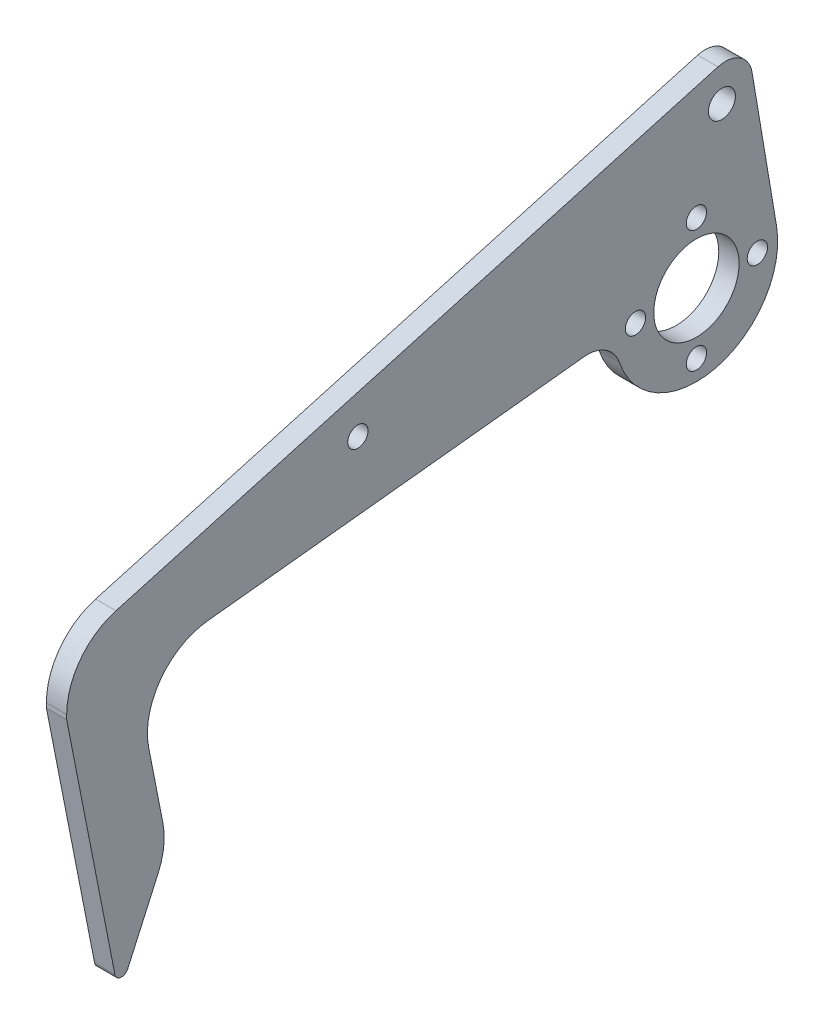
from build123d import *

# Parameters (mm, degrees)
SKETCH_1_R          = 12
SKETCH_1_R_2        = 1.5
SKETCH_1_R_3        = 6.3
EXTRUDE_1_DEPTH     = 3
EXTRUDE_2_DEPTH     = 3
FILLET_2_R          = 30
FILLET_4_R          = 1
SKETCH_3_R          = 1.5
CUT_EXTRUDE_1_DEPTH = 3
FILLET_6_R          = 3
SKETCH_5_R          = 2
EXTRUDE_3_DEPTH     = 3
FILLET_8_R          = 3
CUT_EXTRUDE_2_DEPTH = 10
EXTRUDE_4_DEPTH     = 3
CUT_EXTRUDE_4_DEPTH = 88.351282371
EXTRUDE_5_DEPTH     = 3
EXTRUDE_6_DEPTH     = 3
FILLET_9_R          = 10
FILLET_10_R         = 1
EXTRUDE_8_DEPTH     = 3
FILLET_11_R         = 5


with BuildPart() as part:
    # 草图1 → 凸台-拉伸1 (new body)
    with BuildSketch(Plane(origin=(0, 0, 0), x_dir=(0, 0, -1), z_dir=(1, 0, 0))):
        Circle(SKETCH_1_R)
        with Locations((0, 9)):
            Circle(SKETCH_1_R_2, mode=Mode.SUBTRACT)
        Circle(SKETCH_1_R_3, mode=Mode.SUBTRACT)
        with Locations((9, 0)):
            Circle(SKETCH_1_R_2, mode=Mode.SUBTRACT)
        with Locations((0, -9)):
            Circle(SKETCH_1_R_2, mode=Mode.SUBTRACT)
        with Locations((-9, 0)):
            Circle(SKETCH_1_R_2, mode=Mode.SUBTRACT)
    extrude(amount=EXTRUDE_1_DEPTH)

    # 草图4 → 凸台-拉伸2 (add)
    with BuildSketch(Plane.ZY):
        with BuildLine():
            Line((68.504845759, -22.032619578), (78, -30))
            Line((78, -30), (78, 3))
            Line((78, 3), (18.911534819, 13.41889066))
            Line((18.911534819, 13.41889066), (-0.877535827, 11.967870774))
            ThreePointArc((-0.877535827, 11.967870774), (8.169136125, 8.790063422), (12, 0))
            ThreePointArc((12, 0), (11.827182716, -2.029223745), (11.313708499, -4))
            Line((11.313708499, -4), (32.009040998, -6.929191455))
            Line((32.009040998, -6.929191455), (67.339599923, -4.571456898))
            Line((67.339599923, -4.571456898), (67.835333173, -12))
            Line((67.835333173, -12), (68.504845759, -22.032619578))
        make_face()
        Polygon((32.009040998, -6.929191455), (67.835333173, -12), (67.339599923, -4.571456898), align=None)
    extrude(amount=-EXTRUDE_2_DEPTH)

    # 圆角2
    fillet_2_edges = [part.edges().sort_by_distance(p)[0] for p in [
        (1.5, 13.41889066, 18.911534819),
    ]]
    fillet(fillet_2_edges, radius=FILLET_2_R)

    # 圆角4
    fillet_4_edges = [part.edges().sort_by_distance(p)[0] for p in [
        (1.5, -30, 78),
    ]]
    fillet(fillet_4_edges, radius=FILLET_4_R)

    # 草图3 → 切除-拉伸1 (cut)
    with BuildSketch(Plane.ZY):
        with Locations((50, 6)):
            Circle(SKETCH_3_R)
    extrude(amount=-CUT_EXTRUDE_1_DEPTH, mode=Mode.SUBTRACT)

    # 圆角6
    fillet_6_edges = [part.edges().sort_by_distance(p)[0] for p in [
        (1.5, -22.032619578, 68.504845759),
    ]]
    fillet(fillet_6_edges, radius=FILLET_6_R)

    # 草图5 → 凸台-拉伸3 (add)
    with BuildSketch(Plane(origin=(3, 0, 0), x_dir=(0, 0, -1), z_dir=(1, 0, 0))):
        with BuildLine():
            Line((11.833611983, 1.991388321), (8.212146403, 23.511559971))
            ThreePointArc((8.212146403, 23.511559971), (6.010394905, 26.448138505), (2.341304536, 26.353380903))
            Line((2.341304536, 26.353380903), (-22.28242614, 12.822865834))
            Line((-22.28242614, 12.822865834), (0.877535827, 11.967870774))
            Line((0.877535827, 11.967870774), (11.833611983, 1.991388321))
        make_face()
        with Locations((3.76079209, 21.676172237)):
            Circle(SKETCH_5_R, mode=Mode.SUBTRACT)
    extrude(amount=-EXTRUDE_3_DEPTH)

    # 圆角8
    fillet_8_edges = [part.edges().sort_by_distance(p)[0] for p in [
        (1.5, 12.822865834, 22.28242614),
    ]]
    fillet(fillet_8_edges, radius=FILLET_8_R)

    # 草图6 → 切除-拉伸2 (cut)
    with BuildSketch(Plane(origin=(3, 0, 0), x_dir=(0, 0, -1), z_dir=(1, 0, 0))):
        with BuildLine():
            ThreePointArc((-11.313708499, -4), (-11.827182716, -2.029223745), (-12, 0))
            Line((-12, 0), (-67.835333173, -6))
            Line((-67.835333173, -6), (-67.835333173, -12))
            Line((-67.835333173, -12), (-11.313708499, -4))
        make_face()
    extrude(amount=-CUT_EXTRUDE_2_DEPTH, mode=Mode.SUBTRACT)

    # 草图7 → 凸台-拉伸4 (add)
    with BuildSketch(Plane(origin=(3, 0, 0), x_dir=(0, 0, -1), z_dir=(1, 0, 0))):
        with BuildLine():
            ThreePointArc((-76.35721239, -28.621537523), (-77.422618262, -28.761800867), (-78, -27.855493079))
            Line((-78, -27.855493079), (-78, -39.207735307))
            Line((-78, -39.207735307), (-65.698458682, -28.885516524))
            Line((-65.698458682, -28.885516524), (-67.835333173, -9))
            Line((-67.835333173, -9), (-67.835333173, -12))
            Line((-67.835333173, -12), (-68.419679282, -20.756403294))
            ThreePointArc((-68.419679282, -20.756403294), (-68.737840819, -21.914368693), (-69.484658626, -22.854780194))
            Line((-69.484658626, -22.854780194), (-76.35721239, -28.621537523))
        make_face()
    extrude(amount=-EXTRUDE_4_DEPTH)

    # 草图9 → 切除-拉伸4 (cut, through all)
    with BuildSketch(Plane(origin=(3, 0, 0), x_dir=(0, 0, -1), z_dir=(1, 0, 0))):
        Polygon((-51.477915802, -4.242250943), (-102.730700366, -9.749815596), (-98.933525576, -45.085902185), (-47.680741012, -39.578337532), align=None)
    extrude(amount=-CUT_EXTRUDE_4_DEPTH, mode=Mode.SUBTRACT)

    # 草图10 → 凸台-拉伸5 (add)
    with BuildSketch(Plane.ZY):
        Polygon((78, -7.092283282), (93, -8.704165846), (93, 0.355095289), (78, 3), align=None)
    extrude(amount=-EXTRUDE_5_DEPTH)

    # 草图11 → 凸台-拉伸6 (add)
    with BuildSketch(Plane.ZY):
        Polygon((93, -8.704165846), (85.276239998, -47.951376338), (78.172649999, -32.159084028), (83, -7.62957747), align=None)
    extrude(amount=-EXTRUDE_6_DEPTH)

    # 圆角9
    fillet_9_edges = [part.edges().sort_by_distance(p)[0] for p in [
        (1.5, 0.355095289, 93),
        (1.5, -32.159084028, 78.172649999),
        (1.5, -7.62957747, 83),
    ]]
    fillet(fillet_9_edges, radius=FILLET_9_R)

    # 圆角10
    fillet_10_edges = [part.edges().sort_by_distance(p)[0] for p in [
        (1.5, -47.951376338, 85.276239998),
    ]]
    fillet(fillet_10_edges, radius=FILLET_10_R)

    # 草图12 → 凸台-拉伸8 (add)
    with BuildSketch(Plane(origin=(3, 0, 0), x_dir=(0, 0, -1), z_dir=(1, 0, 0))):
        with BuildLine():
            Line((3.180339281, 26.697159193), (-85.718174485, 1.587587299))
            ThreePointArc((-85.718174485, 1.587587299), (-85.230157098, 1.712247485), (-84.736481777, 1.812176508))
            Line((-84.736481777, 1.812176508), (-22.766810048, 12.739101619))
            ThreePointArc((-22.766810048, 12.739101619), (-22.291557819, 12.863755981), (-21.843026177, 13.064312099))
            Line((-21.843026177, 13.064312099), (2.341304536, 26.353380903))
            ThreePointArc((2.341304536, 26.353380903), (2.751049335, 26.549121258), (3.180339281, 26.697159193))
        make_face()
    extrude(amount=-EXTRUDE_8_DEPTH)

    # 圆角11
    fillet_11_edges = [part.edges().sort_by_distance(p)[0] for p in [
        (1.5, 0, 12),
    ]]
    fillet(fillet_11_edges, radius=FILLET_11_R)


solid = part.part
